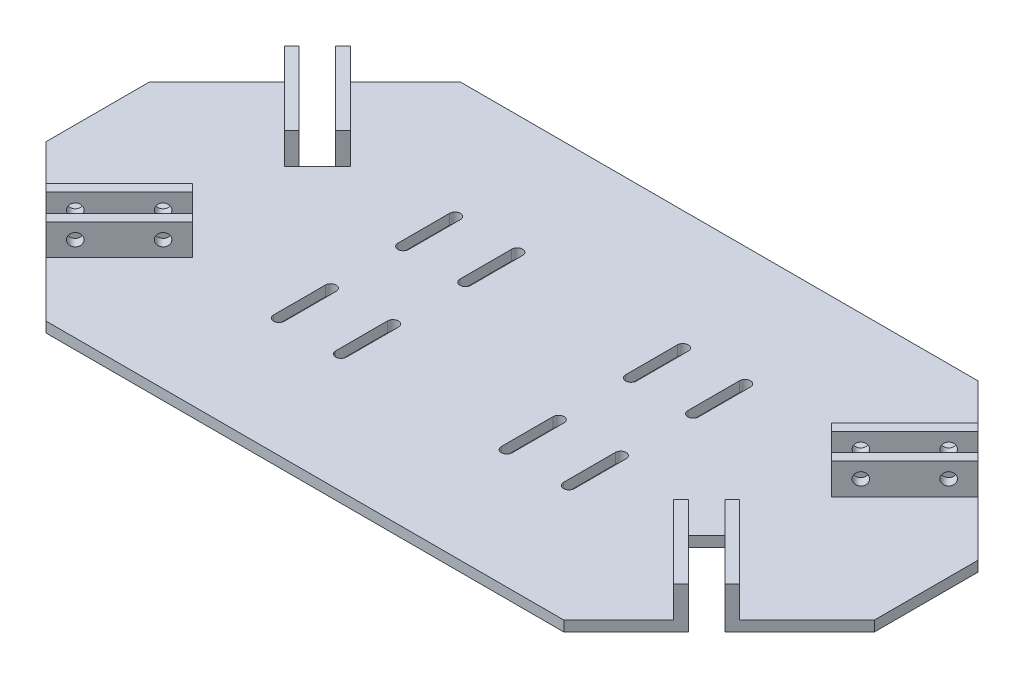
from build123d import *

# Parameters (mm, degrees)
ESQUISSE1_W             = 160
ESQUISSE1_H             = 80
BOSS_EXTRU_1_DEPTH      = 2
ENL_V_MAT_EXTRU_2_DEPTH = 2
ENL_V_MAT_EXTRU_3_DEPTH = 2
BOSS_EXTRU_2_DEPTH      = 6
ENL_V_MAT_EXTRU_4_REACH = 10
D_GAGEMENT_M21_D        = 2.4
D_GAGEMENT_M22_D        = 2.4
D_GAGEMENT_M23_D        = 2.4
D_GAGEMENT_M24_D        = 2.4


with BuildPart() as part:
    # Esquisse1 → Boss.-Extru.1 (new body)
    with BuildSketch(Plane(origin=(0, 0, 0), x_dir=(1, 0, 0), z_dir=(0, 1, 0))):
        with Locations((80, 40)):
            Rectangle(ESQUISSE1_W, ESQUISSE1_H)
    extrude(amount=BOSS_EXTRU_1_DEPTH)

    # Esquisse2 → Enlèv. mat.-Extru.2 (cut)
    with BuildSketch(Plane(origin=(0, 2, 0), x_dir=(1, 0, 0), z_dir=(0, 1, 0))):
        Polygon((0, 50), (30, 80), (0, 80), align=None)
        Polygon((130, 80), (160, 50), (160, 80), align=None)
        Polygon((130, 0), (160, 30), (160, 0), align=None)
        Polygon((0, 30), (30, 0), (0, 0), align=None)
    extrude(amount=-ENL_V_MAT_EXTRU_2_DEPTH, mode=Mode.SUBTRACT)

    # Esquisse7 → Enlèv. mat.-Extru.3 (cut)
    with BuildSketch(Plane(origin=(0, 2, 0), x_dir=(1, 0, 0), z_dir=(0, 1, 0))):
        with BuildLine():
            Line((62.95, 23), (62.95, 33))
            ThreePointArc((62.95, 33), (64, 34.05), (65.05, 33))
            Line((65.05, 33), (65.05, 23))
            ThreePointArc((65.05, 23), (64, 21.95), (62.95, 23))
        make_face()
        with BuildLine():
            Line((50.95, 23), (50.95, 33))
            ThreePointArc((50.95, 33), (52, 34.05), (53.05, 33))
            Line((53.05, 33), (53.05, 23))
            ThreePointArc((53.05, 23), (52, 21.95), (50.95, 23))
        make_face()
        with BuildLine():
            Line((50.95, 47), (50.95, 57))
            ThreePointArc((50.95, 57), (52, 58.05), (53.05, 57))
            Line((53.05, 57), (53.05, 47))
            ThreePointArc((53.05, 47), (52, 45.95), (50.95, 47))
        make_face()
        with BuildLine():
            Line((62.95, 47), (62.95, 57))
            ThreePointArc((62.95, 57), (64, 58.05), (65.05, 57))
            Line((65.05, 57), (65.05, 47))
            ThreePointArc((65.05, 47), (64, 45.95), (62.95, 47))
        make_face()
        with BuildLine():
            Line((97.05, 47), (97.05, 57))
            ThreePointArc((97.05, 57), (96, 58.05), (94.95, 57))
            Line((94.95, 57), (94.95, 47))
            ThreePointArc((94.95, 47), (96, 45.95), (97.05, 47))
        make_face()
        with BuildLine():
            Line((109.05, 47), (109.05, 57))
            ThreePointArc((109.05, 57), (108, 58.05), (106.95, 57))
            Line((106.95, 57), (106.95, 47))
            ThreePointArc((106.95, 47), (108, 45.95), (109.05, 47))
        make_face()
        with BuildLine():
            Line((109.05, 23), (109.05, 33))
            ThreePointArc((109.05, 33), (108, 34.05), (106.95, 33))
            Line((106.95, 33), (106.95, 23))
            ThreePointArc((106.95, 23), (108, 21.95), (109.05, 23))
        make_face()
        with BuildLine():
            Line((97.05, 23), (97.05, 33))
            ThreePointArc((97.05, 33), (96, 34.05), (94.95, 33))
            Line((94.95, 33), (94.95, 23))
            ThreePointArc((94.95, 23), (96, 21.95), (97.05, 23))
        make_face()
    extrude(amount=-ENL_V_MAT_EXTRU_3_DEPTH, mode=Mode.SUBTRACT)

    # Esquisse8 → Boss.-Extru.2 (add)
    with BuildSketch(Plane(origin=(0, 2, 0), x_dir=(1, 0, 0), z_dir=(0, 1, 0))):
        Polygon((13.029437252, 16.970562748), (19.393398282, 10.606601718), (33.535533906, 24.748737342), (27.171572875, 31.112698372), align=None)
        Polygon((19.393398282, 69.393398282), (13.029437252, 63.029437252), (27.171572875, 48.887301628), (33.535533906, 55.251262658), align=None)
        Polygon((149.393398282, 60.606601718), (143.029437252, 66.970562748), (128.887301628, 52.828427125), (135.251262658, 46.464466094), align=None)
        Polygon((146.970562748, 16.970562748), (140.606601718, 10.606601718), (126.464466094, 24.748737342), (132.828427125, 31.112698372), align=None)
    extrude(amount=BOSS_EXTRU_2_DEPTH)

    # Esquisse10 → Enlèv. mat.-Extru.4 (cut, up to next)
    with BuildSketch(Plane(origin=(0, 8, 0), x_dir=(1, 0, 0), z_dir=(0, 1, 0)), mode=Mode.PRIVATE) as enl_v_mat_extru_4_sk1:
        Polygon((17.97918472, 12.02081528), (14.443650814, 15.556349186), (28.585786438, 29.69848481), (32.121320344, 26.162950904), align=None)
    enl_v_mat_extru_4_tool1 = extrude(enl_v_mat_extru_4_sk1.sketch, amount=-ENL_V_MAT_EXTRU_4_REACH, mode=Mode.PRIVATE) & part.part
    add(enl_v_mat_extru_4_tool1.solids().sort_by_distance((23.282486, 8, -20.85965))[0], mode=Mode.SUBTRACT)
    # Esquisse10 → Enlèv. mat.-Extru.4 (cut, up to next)
    with BuildSketch(Plane(origin=(0, 8, 0), x_dir=(1, 0, 0), z_dir=(0, 1, 0)), mode=Mode.PRIVATE) as enl_v_mat_extru_4_sk2:
        Polygon((14.443650814, 64.443650814), (17.97918472, 67.97918472), (32.121320344, 53.837049096), (28.585786438, 50.30151519), align=None)
    enl_v_mat_extru_4_tool2 = extrude(enl_v_mat_extru_4_sk2.sketch, amount=-ENL_V_MAT_EXTRU_4_REACH, mode=Mode.PRIVATE) & part.part
    add(enl_v_mat_extru_4_tool2.solids().sort_by_distance((23.282486, 8, -59.14035))[0], mode=Mode.SUBTRACT)
    # Esquisse10 → Enlèv. mat.-Extru.4 (cut, up to next)
    with BuildSketch(Plane(origin=(0, 8, 0), x_dir=(1, 0, 0), z_dir=(0, 1, 0)), mode=Mode.PRIVATE) as enl_v_mat_extru_4_sk3:
        Polygon((144.443650814, 65.556349186), (147.97918472, 62.02081528), (133.837049096, 47.878679656), (130.30151519, 51.414213562), align=None)
    enl_v_mat_extru_4_tool3 = extrude(enl_v_mat_extru_4_sk3.sketch, amount=-ENL_V_MAT_EXTRU_4_REACH, mode=Mode.PRIVATE) & part.part
    add(enl_v_mat_extru_4_tool3.solids().sort_by_distance((139.14035, 8, -56.717514))[0], mode=Mode.SUBTRACT)
    # Esquisse10 → Enlèv. mat.-Extru.4 (cut, up to next)
    with BuildSketch(Plane(origin=(0, 8, 0), x_dir=(1, 0, 0), z_dir=(0, 1, 0)), mode=Mode.PRIVATE) as enl_v_mat_extru_4_sk4:
        Polygon((145.556349186, 15.556349186), (142.02081528, 12.02081528), (127.878679656, 26.162950904), (131.414213562, 29.69848481), align=None)
    enl_v_mat_extru_4_tool4 = extrude(enl_v_mat_extru_4_sk4.sketch, amount=-ENL_V_MAT_EXTRU_4_REACH, mode=Mode.PRIVATE) & part.part
    add(enl_v_mat_extru_4_tool4.solids().sort_by_distance((136.717514, 8, -20.85965))[0], mode=Mode.SUBTRACT)

    # Dégagement M21 (through all)
    with Locations(Plane(origin=(4.393398282, 0, 4.393398282), x_dir=(0.707106781, 0, -0.707106781), z_dir=(0.707106781, 0, 0.707106781))):
        with Locations((25.213203436, 5), (37.213203436, 5)):
            Hole(D_GAGEMENT_M21_D / 2)

    # Dégagement M22 (through all)
    with Locations(Plane(origin=(38.029437252, 0, -38.029437252), x_dir=(0.707106781, 0, 0.707106781), z_dir=(-0.707106781, 0, 0.707106781))):
        with Locations((-31.355339059, 5), (-19.355339059, 5)):
            Hole(D_GAGEMENT_M22_D / 2)

    # Dégagement M23 (through all)
    with Locations(Plane(origin=(75.606601718, 0, -75.606601718), x_dir=(0.707106781, 0, 0.707106781), z_dir=(-0.707106781, 0, 0.707106781))):
        with Locations((75.923881554, 5), (87.923881554, 5)):
            Hole(D_GAGEMENT_M23_D / 2)

    # Dégagement M24 (through all)
    with Locations(Plane(origin=(38.029437252, 0, 38.029437252), x_dir=(-0.707106781, 0, 0.707106781), z_dir=(-0.707106781, 0, -0.707106781))):
        with Locations((-144.492424049, 5), (-132.492424049, 5)):
            Hole(D_GAGEMENT_M24_D / 2)


solid = part.part
